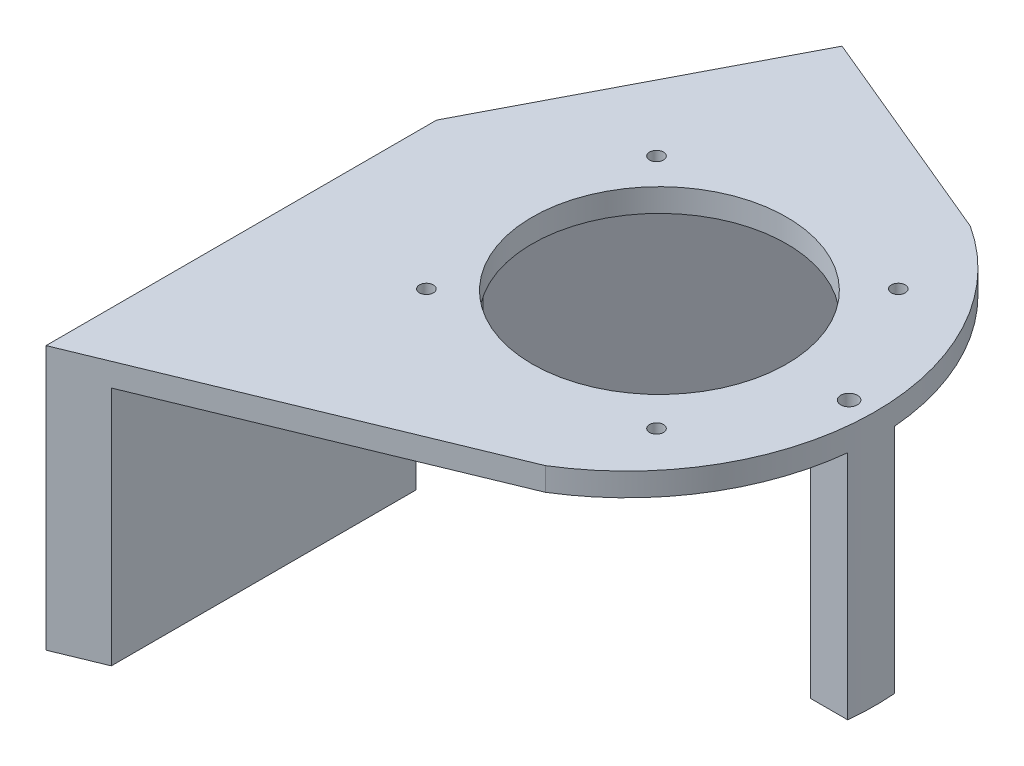
from build123d import *

# Parameters (mm, degrees)
SKETCH2_R           = 13.75
SKETCH2_R_2         = 0.75
BOSS_EXTRUDE1_DEPTH = 2.5
BOSS_EXTRUDE2_DEPTH = 26
SKETCH5_W           = 7.2
SKETCH5_H           = 21
BOSS_EXTRUDE5_DEPTH = 5
BOSS_EXTRUDE6_DEPTH = 25
SKETCH7_R           = 0.9
CUT_EXTRUDE1_DEPTH  = 10


with BuildPart() as part:
    # Sketch2 → Boss-Extrude1 (new body)
    with BuildSketch(Plane(origin=(0, 0, 0), x_dir=(1, 0, 0), z_dir=(0, 1, 0))):
        with BuildLine():
            Line((104.5, -77.2), (142.702591635, -61.456260882))
            ThreePointArc((142.702591635, -61.456260882), (155.478803114, -38.915145373), (143.235603671, -16.080138573))
            Line((143.235603671, -16.080138573), (119.48341621, -6.174842748))
            Line((119.48341621, -6.174842748), (104.5, -35))
            Line((104.5, -35), (104.5, -77.2))
        make_face()
        with Locations((132.490326991, -38.915145373)):
            Circle(SKETCH2_R, mode=Mode.SUBTRACT)
        with Locations((145.236491006, -25.853835985)):
            Circle(SKETCH2_R_2, mode=Mode.SUBTRACT)
        with Locations((119.744162977, -51.346164015)):
            Circle(SKETCH2_R_2, mode=Mode.SUBTRACT)
        with Locations((119.744162977, -26.484126731)):
            Circle(SKETCH2_R_2, mode=Mode.SUBTRACT)
        with Locations((145.236491006, -51.97645476)):
            Circle(SKETCH2_R_2, mode=Mode.SUBTRACT)
    extrude(amount=BOSS_EXTRUDE1_DEPTH)

    # Sketch3 → Boss-Extrude2 (add)
    with BuildSketch(Plane.XZ):
        Polygon((104.5, 42.2), (109.5, 42.2), (109.5, 75.139440959), (104.5, 77.2), align=None)
        Polygon((109.5, 35), (104.5, 35), (119.48341621, 6.174842748), (123.601295817, 7.871869559), align=None)
    extrude(amount=BOSS_EXTRUDE2_DEPTH)

    # Sketch5 → Boss-Extrude5 (add)
    with BuildSketch(Plane.ZY.offset(-104.5)):
        with Locations((38.6, -10.5)):
            Rectangle(SKETCH5_W, SKETCH5_H)
    extrude(amount=-BOSS_EXTRUDE5_DEPTH)

    # Sketch6 → Boss-Extrude6 (add)
    with BuildSketch(Plane.XZ):
        with BuildLine():
            Line((155.332558904, 41.415145373), (151.332558904, 41.415145373))
            Line((151.332558904, 41.415145373), (151.332558904, 36.415145373))
            Line((151.332558904, 36.415145373), (155.391548261, 36.415145373))
            ThreePointArc((155.391548261, 36.415145373), (155.478786901, 38.916522577), (155.332558904, 41.415145373))
        make_face()
    extrude(amount=BOSS_EXTRUDE6_DEPTH)

    # Sketch7 → Cut-Extrude1 (cut)
    with BuildSketch(Plane(origin=(0, 2.5, 0), x_dir=(1, 0, 0), z_dir=(0, 1, 0))):
        with Locations((152.978803114, -38.915145373)):
            Circle(SKETCH7_R)
    extrude(amount=-CUT_EXTRUDE1_DEPTH, mode=Mode.SUBTRACT)


solid = part.part
